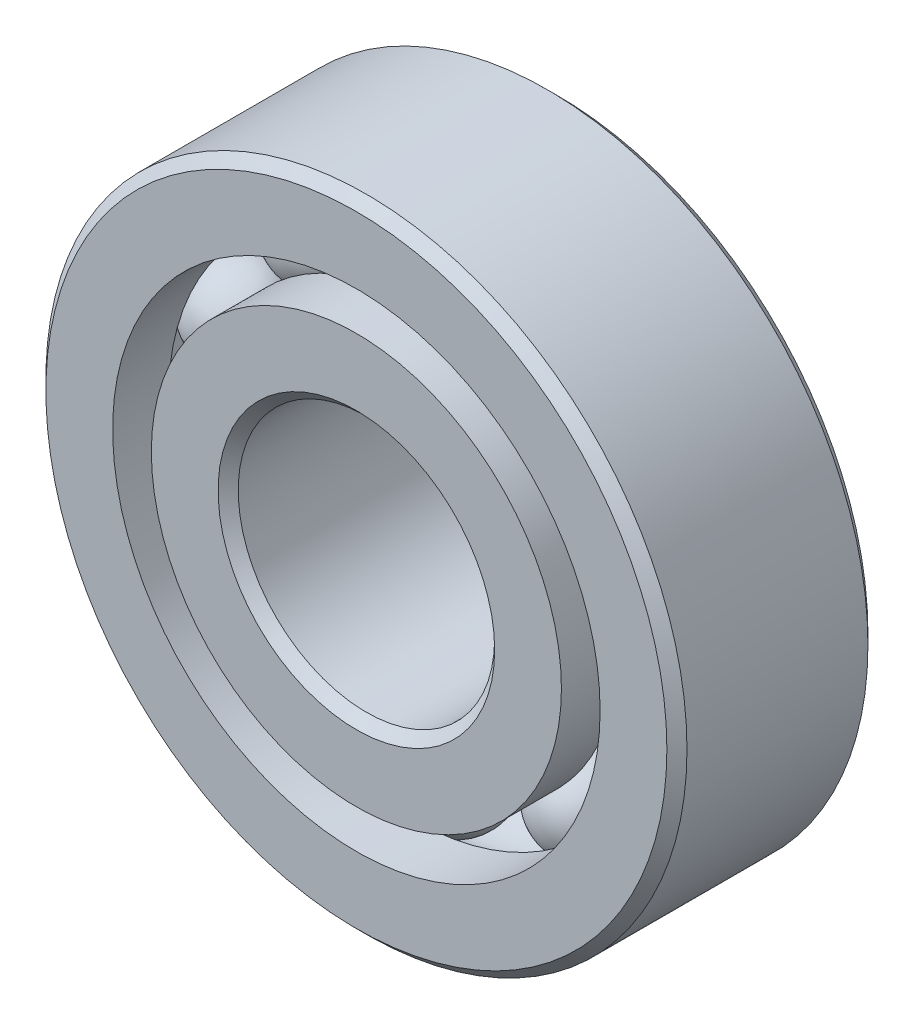
from build123d import *

# Parameters (mm, degrees)
CIRPATTERN1_COUNT = 10


with BuildPart() as part:
    # Sketch1 → Revolve1 (revolve)
    with BuildSketch(Plane(origin=(0, 0, 0), x_dir=(0, 0, -1), z_dir=(1, 0, 0))):
        with BuildLine():
            Line((2.24028, 7.9375), (-2.24028, 7.9375))
            Line((-2.24028, 7.9375), (-2.4892, 7.68858))
            Line((-2.4892, 7.68858), (-2.4892, 6.035221429))
            Line((-2.4892, 6.035221429), (-1.106311111, 6.035221429))
            ThreePointArc((-1.106311111, 6.035221429), (0, 6.76179465), (1.106311111, 6.035221429))
            Line((1.106311111, 6.035221429), (2.4892, 6.035221429))
            Line((2.4892, 6.035221429), (2.4892, 7.68858))
            Line((2.4892, 7.68858), (2.24028, 7.9375))
        make_face()
    revolve(axis=Axis((0, 0, 2.4892), (0, 0, -1)))


with BuildPart() as body_2:
    # Sketch3 → Revolve3 (revolve)
    with BuildSketch(Plane(origin=(0, 0, 0), x_dir=(0, 0, -1), z_dir=(1, 0, 0))):
        with BuildLine():
            Line((-2.4892, 5.077278571), (-1.106311111, 5.077278571))
            ThreePointArc((-1.106311111, 5.077278571), (0, 4.35070535), (1.106311111, 5.077278571))
            Line((1.106311111, 5.077278571), (2.4892, 5.077278571))
            Line((2.4892, 5.077278571), (2.4892, 3.42392))
            Line((2.4892, 3.42392), (2.24028, 3.175))
            Line((2.24028, 3.175), (-2.24028, 3.175))
            Line((-2.24028, 3.175), (-2.4892, 3.42392))
            Line((-2.4892, 3.42392), (-2.4892, 5.077278571))
        make_face()
    revolve(axis=Axis((0, 0, 2.4892), (0, 0, -1)))


with BuildPart() as body_3:
    # Sketch4 → Revolve4 (revolve)
    with BuildSketch(Plane(origin=(0, 0, 0), x_dir=(0, 0, -1), z_dir=(1, 0, 0))):
        with BuildLine():
            Line((-1.20554465, 5.55625), (1.20554465, 5.55625))
            ThreePointArc((1.20554465, 5.55625), (0, 6.76179465), (-1.20554465, 5.55625))
        make_face()
    revolve(axis=Axis((0, 5.55625, 1.20554465), (0, 0, -1)))


with BuildPart() as cirpattern1_1:
    # CirPattern1: pattern copy
    add(body_3.part.rotate(Axis((0, 0, -2.4892), (0, 0, 1)), 1 * 360 / CIRPATTERN1_COUNT))


with BuildPart() as cirpattern1_2:
    # CirPattern1: pattern copy
    add(body_3.part.rotate(Axis((0, 0, -2.4892), (0, 0, 1)), 2 * 360 / CIRPATTERN1_COUNT))


with BuildPart() as cirpattern1_3:
    # CirPattern1: pattern copy
    add(body_3.part.rotate(Axis((0, 0, -2.4892), (0, 0, 1)), 3 * 360 / CIRPATTERN1_COUNT))


with BuildPart() as cirpattern1_4:
    # CirPattern1: pattern copy
    add(body_3.part.rotate(Axis((0, 0, -2.4892), (0, 0, 1)), 4 * 360 / CIRPATTERN1_COUNT))


with BuildPart() as cirpattern1_5:
    # CirPattern1: pattern copy
    add(body_3.part.rotate(Axis((0, 0, -2.4892), (0, 0, 1)), 5 * 360 / CIRPATTERN1_COUNT))


with BuildPart() as cirpattern1_6:
    # CirPattern1: pattern copy
    add(body_3.part.rotate(Axis((0, 0, -2.4892), (0, 0, 1)), 6 * 360 / CIRPATTERN1_COUNT))


with BuildPart() as cirpattern1_7:
    # CirPattern1: pattern copy
    add(body_3.part.rotate(Axis((0, 0, -2.4892), (0, 0, 1)), 7 * 360 / CIRPATTERN1_COUNT))


with BuildPart() as cirpattern1_8:
    # CirPattern1: pattern copy
    add(body_3.part.rotate(Axis((0, 0, -2.4892), (0, 0, 1)), 8 * 360 / CIRPATTERN1_COUNT))


with BuildPart() as cirpattern1_9:
    # CirPattern1: pattern copy
    add(body_3.part.rotate(Axis((0, 0, -2.4892), (0, 0, 1)), 9 * 360 / CIRPATTERN1_COUNT))


solid = Compound([part.part, body_2.part, body_3.part, cirpattern1_1.part, cirpattern1_2.part, cirpattern1_3.part, cirpattern1_4.part, cirpattern1_5.part, cirpattern1_6.part, cirpattern1_7.part, cirpattern1_8.part, cirpattern1_9.part])
